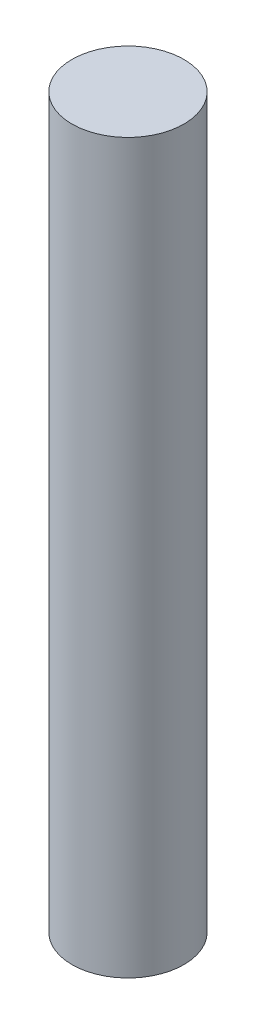
from build123d import *

# Parameters (mm, degrees)
SKETCH1_R           = 152.4
BOSS_EXTRUDE1_DEPTH = 1981.2


with BuildPart() as part:
    # Sketch1 → Boss-Extrude1 (new body)
    with BuildSketch(Plane(origin=(0, 0, 0), x_dir=(1, 0, 0), z_dir=(0, 1, 0))):
        Circle(SKETCH1_R)
    extrude(amount=BOSS_EXTRUDE1_DEPTH)


solid = part.part
